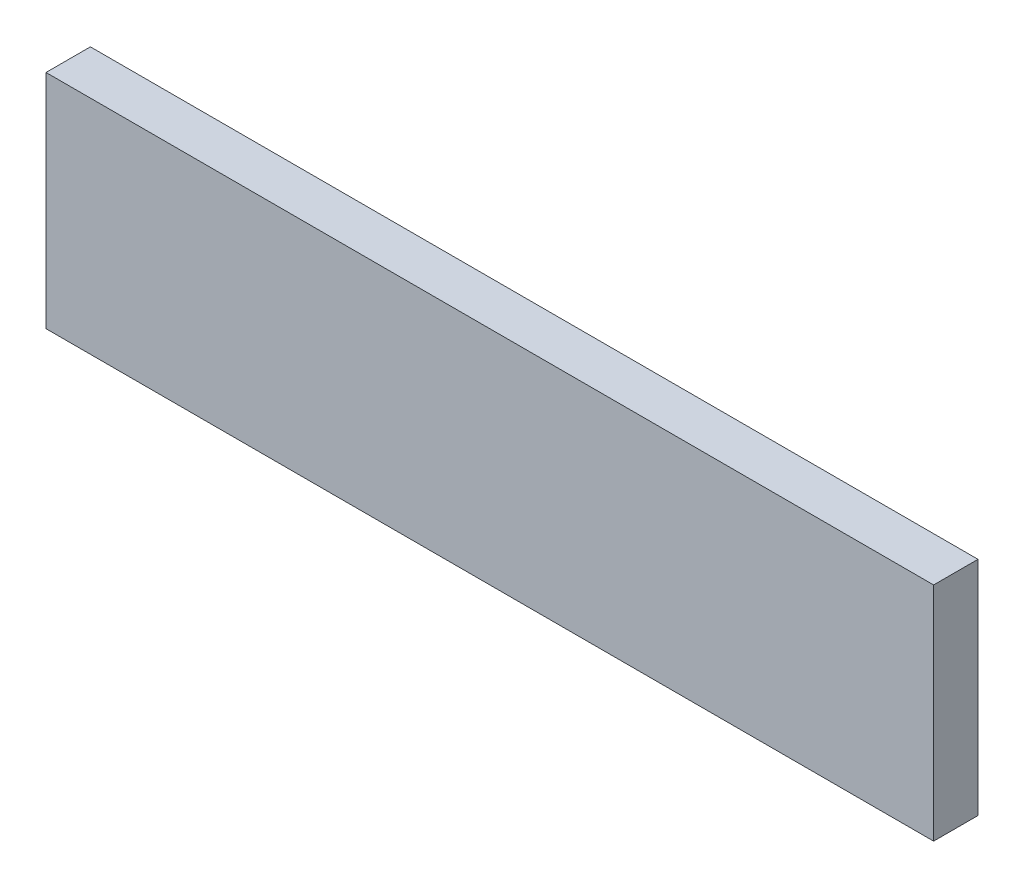
from build123d import *

# Parameters (mm, degrees)
SKETCH_1_W      = 10
SKETCH_1_H      = 50
EXTRUDE_1_DEPTH = 200


with BuildPart() as part:
    # Эскиз1 → Бобышка-Вытянуть1 (new body)
    with BuildSketch(Plane(origin=(0, 0, 0), x_dir=(0, 0, -1), z_dir=(1, 0, 0))):
        with Locations((5, 25)):
            Rectangle(SKETCH_1_W, SKETCH_1_H)
    extrude(amount=EXTRUDE_1_DEPTH)


solid = part.part
